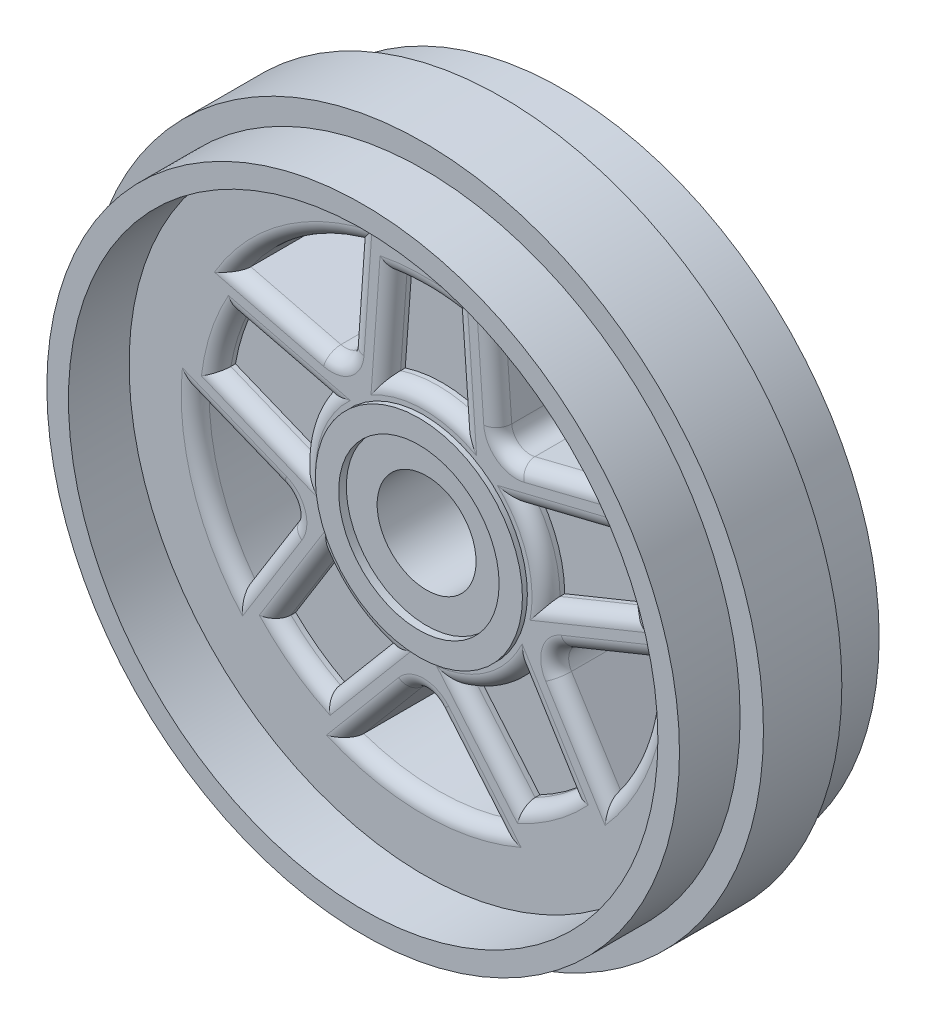
from build123d import *

# Parameters (mm, degrees)
SKETCH1_R           = 8.6106
SKETCH1_R_2         = 2.8194
BOSS_EXTRUDE1_DEPTH = 5.4356
SKETCH3_R           = 9.2456
BOSS_EXTRUDE2_DEPTH = 5.4356
SKETCH4_R           = 9.245600000000001
SKETCH4_R_2         = 8.6106
CUT_EXTRUDE1_DEPTH  = 1.6509999999999998
CUT_EXTRUDE2_START  = -1.6509999999999998
SKETCH5_R           = 9.245600000000001
SKETCH5_R_2         = 8.6106
CUT_EXTRUDE2_DEPTH  = 1.6509999999999998
SKETCH6_R           = 8.022894388156118
SKETCH6_R_2         = 2.8194
CUT_EXTRUDE3_DEPTH  = 1.6509999999999998
SKETCH7_R           = 2.8194
SKETCH7_R_2         = 2.1844
CUT_EXTRUDE4_DEPTH  = 1.5165564155091538
SKETCH8_R           = 2.1844
SKETCH8_R_2         = 1.524
CUT_EXTRUDE5_DEPTH  = 1.7272
SKETCH9_R           = 1.3461999999999998
CUT_EXTRUDE6_DEPTH  = 15.160084253986629
SKETCH10_R          = 1.524
SKETCH10_R_2        = 1.3461999999999998
CUT_EXTRUDE7_DEPTH  = 1.7272
CUT_EXTRUDE9_DEPTH  = 0.508
CUT_EXTRUDE10_DEPTH = 14.61195929614837
FILLET1_R           = 0.381
SCALE1_SCALE        = 0.5


with BuildPart() as part:
    # Sketch1 → Boss-Extrude1 (new body)
    with BuildSketch(Plane.XY):
        Circle(SKETCH1_R)
        Circle(SKETCH1_R_2, mode=Mode.SUBTRACT)
    extrude(amount=-BOSS_EXTRUDE1_DEPTH)

    # Sketch3 → Boss-Extrude2 (add, through all)
    with BuildSketch(Plane.XY):
        Circle(SKETCH3_R)
    extrude(amount=-BOSS_EXTRUDE2_DEPTH)

    # Sketch4 → Cut-Extrude1 (cut)
    with BuildSketch(Plane.XY):
        Circle(SKETCH4_R)
        Circle(SKETCH4_R_2, mode=Mode.SUBTRACT)
    extrude(amount=-CUT_EXTRUDE1_DEPTH, mode=Mode.SUBTRACT)

    # Sketch5 → Cut-Extrude2 (cut)
    with BuildSketch(Plane(origin=(0, 0, -5.4356), x_dir=(-1, 0, 0), z_dir=(0, 0, -1)).offset(CUT_EXTRUDE2_START)):
        with Locations(Location((0, 0, 0), (0, 0, 180))):
            Circle(SKETCH5_R)
        with Locations(Location((0, 0, 0), (0, 0, 180))):
            Circle(SKETCH5_R_2, mode=Mode.SUBTRACT)
    extrude(amount=CUT_EXTRUDE2_DEPTH, mode=Mode.SUBTRACT)

    # Sketch6 → Cut-Extrude3 (cut)
    with BuildSketch(Plane.XY):
        Circle(SKETCH6_R)
        Circle(SKETCH6_R_2, mode=Mode.SUBTRACT)
    extrude(amount=-CUT_EXTRUDE3_DEPTH, mode=Mode.SUBTRACT)

    # Sketch7 → Cut-Extrude4 (cut)
    with BuildSketch(Plane.XY):
        Circle(SKETCH7_R)
        Circle(SKETCH7_R_2, mode=Mode.SUBTRACT)
    extrude(amount=-CUT_EXTRUDE4_DEPTH, mode=Mode.SUBTRACT)

    # Sketch8 → Cut-Extrude5 (cut)
    with BuildSketch(Plane.XY):
        Circle(SKETCH8_R)
        Circle(SKETCH8_R_2, mode=Mode.SUBTRACT)
    extrude(amount=-CUT_EXTRUDE5_DEPTH, mode=Mode.SUBTRACT)

    # Sketch9 → Cut-Extrude6 (cut, through all)
    with BuildSketch(Plane.XY):
        Circle(SKETCH9_R)
    extrude(amount=-CUT_EXTRUDE6_DEPTH, mode=Mode.SUBTRACT)

    # Sketch10 → Cut-Extrude7 (cut)
    with BuildSketch(Plane.XY):
        Circle(SKETCH10_R)
        Circle(SKETCH10_R_2, mode=Mode.SUBTRACT)
    extrude(amount=-CUT_EXTRUDE7_DEPTH, mode=Mode.SUBTRACT)

    # Sketch11 → Cut-Extrude9 (cut)
    with BuildSketch(Plane.XY.offset(-1.6509999999999998)):
        with BuildLine():
            ThreePointArc((-2.701714558806702, 1.942248491499446), (-3.1645454523204806, 1.028223147083241), (-3.3273580116155173, 0.01671593664837479))
            Line((-3.3273580116155173, 0.01671593664837479), (-5.634526430218111, 0.9556866155667996))
            ThreePointArc((-5.634526430218111, 0.9556866155667996), (-5.5497173611167945, 1.3645007188414797), (-5.435287990626782, 1.7660321228528866))
            ThreePointArc((-5.435287990626782, 1.7660321228528866), (-5.291849058398618, 2.1581377488764804), (-5.120166135744675, 2.538724826044256))
            Line((-5.120166135744675, 2.538724826044256), (-2.701714558806702, 1.942248491499446))
        make_face()
        with BuildLine():
            ThreePointArc((-1.0123123714834512, 3.169671027495056), (-0.5122633029570205, 3.287731295048844), (8.354e-14, 3.3273999999999946))
            Line((0, 3.3273999999999946), (0, 5.715000000000001))
            ThreePointArc((3.5e-16, 5.715000000000001), (-0.41723967841923076, 5.69974877084531), (-0.8322524389214009, 5.654076483203014))
            Line((-0.8322524389214008, 5.6540764832030135), (-1.0123123714834508, 3.169671027495055))
        make_face()
        with BuildLine():
            Line((0, 5.715000000000001), (0, 3.3273999999999946))
            ThreePointArc((8.354e-14, 3.3273999999999946), (0.5122633029571078, 3.287731295048827), (1.0123123714834603, 3.1696710274950473))
            Line((1.01231237148346, 3.169671027495046), (0.8322524389213971, 5.654076483203016))
            ThreePointArc((0.8322524389213972, 5.654076483203017), (0.41723967841922904, 5.69974877084531), (3.5e-16, 5.715000000000001))
        make_face()
        with BuildLine():
            ThreePointArc((3.327358011615513, 0.01671593664831592), (3.1645454523204894, 1.028223147083182), (2.701714558806741, 1.942248491499402))
            Line((2.701714558806741, 1.942248491499402), (5.120166135744708, 2.5387248260441866))
            ThreePointArc((5.120166135744708, 2.5387248260441866), (5.291849058398644, 2.158137748876405), (5.435287990626809, 1.7660321228528089))
            ThreePointArc((5.435287990626809, 1.7660321228528089), (5.54971736111681, 1.364500718841401), (5.634526430218126, 0.955686615566724))
            Line((5.634526430218126, 0.955686615566724), (3.327358011615513, 0.01671593664831592))
        make_face()
        with BuildLine():
            ThreePointArc((1.0441079724341762, -3.1593400104925973), (1.9557966484779505, -2.6919231470832092), (2.6820637967264287, -1.9692954451502238))
            Line((2.6820637967264287, -1.9692954451502238), (3.99668913885781, -4.085058252624556))
            ThreePointArc((3.99668913885781, -4.085058252624556), (3.687782259843692, -4.365946289635513), (3.359192716851457, -4.623532122852843))
            ThreePointArc((3.359192716851457, -4.623532122852843), (3.012674278706302, -4.856440948927667), (2.6500764054629875, -5.063429672189431))
            Line((2.6500764054629875, -5.063429672189431), (1.0441079724341762, -3.1593400104925973))
        make_face()
        with BuildLine():
            ThreePointArc((-2.6820637967264593, -1.969295445150172), (-1.955796648478003, -2.6919231470831777), (-1.0441079724342346, -3.1593400104925835))
            Line((-1.0441079724342346, -3.1593400104925835), (-2.650076405463056, -5.063429672189393))
            ThreePointArc((-2.650076405463056, -5.063429672189393), (-3.0126742787063736, -4.856440948927627), (-3.3591927168515245, -4.623532122852795))
            ThreePointArc((-3.3591927168515245, -4.623532122852795), (-3.6877822598437566, -4.365946289635463), (-3.9966891388578683, -4.085058252624502))
            Line((-3.9966891388578683, -4.085058252624502), (-2.6820637967264593, -1.969295445150172))
        make_face()
    extrude(amount=-CUT_EXTRUDE9_DEPTH, mode=Mode.SUBTRACT)

    # Sketch13 → Cut-Extrude10 (cut, through all)
    with BuildSketch(Plane.XY.offset(-1.6509999999999998)):
        with BuildLine():
            ThreePointArc((-2.0146062069009973, -5.887876597816565), (-1.14e-15, -6.222999999999999), (2.0146062069010005, -5.887876597816564))
            Line((2.014606206901003, -5.887876597816565), (0.38547899600946955, -3.954046785178563))
            ThreePointArc((0.38547899600946944, -3.954046785178563), (-0.00349940332045376, -3.7733430580942775), (-0.3921450745334992, -3.954761288641217))
            Line((-0.39214507453349934, -3.954761288641217), (-2.0146062069009987, -5.887876597816565))
        make_face()
        with BuildLine():
            Line((3.6400220016627487, -1.595040575354477), (4.977155850589481, -3.7354582903497797))
            ThreePointArc((4.97715585058948, -3.7354582903497797), (5.903328292506622, -1.9688687287096727), (6.222999999999999, -1.52e-15))
            ThreePointArc((6.222999999999999, 0), (6.222812737282652, 0.04827666841003023), (6.222250960400843, 0.09655043133392485))
            Line((6.222250960400846, 0.0965504313339249), (3.8796415215214846, -0.8552553421241277))
            ThreePointArc((3.8796415215214846, -0.8552553421241279), (3.58758112852144, -1.1693552608889697), (3.6400220016627483, -1.5950405753544772))
        make_face()
        with BuildLine():
            Line((2.6418023913585413, 2.9689719996369655), (5.090657689870749, 3.579236410822818))
            ThreePointArc((5.090657689870748, 3.5792364108228174), (3.6577876250161028, 5.034512755995266), (1.8309563731584468, 5.947548046009419))
            Line((1.8309563731584473, 5.947548046009421), (2.012271328456201, 3.425469914685943))
            ThreePointArc((2.012271328456201, 3.425469914685943), (2.2207464781444433, 3.050641761941401), (2.6418023913585413, 2.9689719996369655))
        make_face()
        with BuildLine():
            ThreePointArc((-1.8309563731583645, 5.947548046009444), (-3.657787625016032, 5.0345127559953164), (-5.090657689870699, 3.579236410822887))
            Line((-5.0906576898707, 3.5792364108228885), (-2.6359894459486606, 2.972312176840224))
            ThreePointArc((-2.6359894459486606, 2.972312176840224), (-2.215084324631561, 3.054755557268604), (-2.0072983322424336, 3.4299661827768464))
            Line((-2.0072983322424336, 3.4299661827768464), (-1.8309563731583647, 5.9475480460094445))
        make_face()
        with BuildLine():
            ThreePointArc((-6.222250960400842, 0.09655043133400902), (-5.918424700904745, -1.923012755995281), (-4.977155850589531, -3.7354582903497113))
            Line((-4.977155850589534, -3.735458290349714), (-3.6414024000384644, -1.5884799642235095))
            ThreePointArc((-3.6414024000384644, -1.5884799642235095), (-3.5897438787138447, -1.1626990002267943), (-3.8823809862453365, -0.8491363184181635))
            Line((-3.8823809862453365, -0.8491363184181636), (-6.222250960400844, 0.09655043133400902))
        make_face()
    extrude(amount=-CUT_EXTRUDE10_DEPTH, mode=Mode.SUBTRACT)

    # Fillet1
    fillet1_edges = [part.edges().sort_by_distance(p)[0] for p in [
        (5.435287990626809, 1.7660321228528102, -1.6509999999999998),
        (4.48094222091682, 0.48620127610751995, -1.6509999999999998),
        (3.9109403472757247, 2.240486658771794, -1.6509999999999998),
        (5.58e-15, 3.3273999999999955, -1.6509999999999998),
        (0.9222824052024285, 4.411873755349031, -1.6509999999999998),
        (-1.82e-15, 5.715000000000002, -1.6509999999999998),
        (-0.9222824052024258, 4.411873755349034, -1.6509999999999998),
        (-3.16454545232048, 1.0282231470832406, -1.6509999999999998),
        (-5.435287990626785, 1.7660321228528826, -1.6509999999999998),
        (-3.9109403472756887, 2.240486658771851, -1.6509999999999998),
        (-4.480942220916814, 0.4862012761075872, -1.6509999999999998),
        (-1.203375640717249, -4.921318943228891, -1.6509999999999998),
        (1.2000426014552363, -4.920961691497563, -1.6509999999999998),
        (-0.00349940332045375, -3.7733430580942775, -1.6509999999999998),
        (1e-15, -6.223000000000001, -1.6509999999999998),
        (4.308588926126115, -2.6652494328521286, -1.6509999999999998),
        (5.050946240961165, -0.37935245539510143, -1.6509999999999998),
        (3.58758112852144, -1.1693552608889697, -1.6509999999999998),
        (5.91842470090569, -1.9230127559960752, -1.6509999999999998),
        (3.8662300406146453, 3.2741042052298917, -1.6509999999999998),
        (1.9216138508073242, 4.686508980347682, -1.6509999999999998),
        (2.2207464781444433, 3.050641761941401, -1.6509999999999998),
        (3.657787625016102, 5.034512755995266, -1.6509999999999998),
        (-1.9191273527003991, 4.6887571143931455, -1.6509999999999998),
        (-3.8633235679096805, 3.275774293831556, -1.6509999999999998),
        (-2.215084324631561, 3.054755557268604, -1.6509999999999998),
        (-3.6577876250160326, 5.034512755995316, -1.6509999999999998),
        (-5.05231597332309, -0.3762929435420773, -1.6509999999999998),
        (-4.309279125313999, -2.6619691272866115, -1.6509999999999998),
        (-3.5897438787138447, -1.1626990002267943, -1.6509999999999998),
        (-5.918424700904745, -1.923012755995282, -1.6509999999999998),
        (-1.9557966484780018, -2.691923147083178, -1.6509999999999998),
        (-3.3591927168515223, -4.623532122852797, -1.6509999999999998),
        (-3.339376467792164, -3.027176848887337, -1.6509999999999998),
        (-1.8470921889486451, -4.111384841340988, -1.6509999999999998),
        (1.9557966484779512, -2.691923147083208, -1.6509999999999998),
        (3.359192716851458, -4.623532122852843, -1.6509999999999998),
        (1.8470921889485818, -4.111384841341014, -1.6509999999999998),
        (3.3393764677921194, -3.0271768488873896, -1.6509999999999998),
        (3.164545452320489, 1.0282231470831826, -1.6509999999999998),
    ]]
    fillet(fillet1_edges, radius=FILLET1_R)


with BuildPart() as part_1:
    # Scale1: scaled about (-1.065e-06, 4.44e-07, -3.338100616)
    add(part.part.scale(SCALE1_SCALE).moved(Location((-5.325e-07, 2.22e-07, -1.669050308))))


solid = part_1.part
